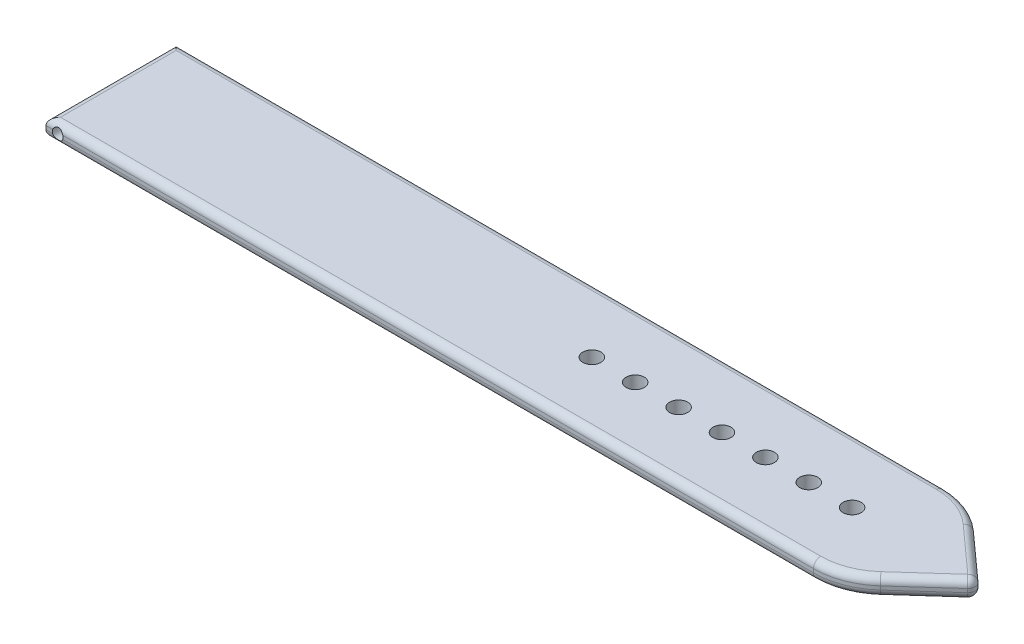
from build123d import *

# Parameters (mm, degrees)
BOSS_EXTRUDE1_DEPTH     = 1.25
FILLET1_R               = 10
FILLET2_R               = 1
FILLET3_R               = 1
SKETCH2_R               = 1.25
CUT_EXTRUDE1_DEPTH      = 3.5
LPATTERN1_COUNT         = 7
LPATTERN1_PITCH         = 6
SKETCH3_R               = 0.75
CUT_EXTRUDE2_DEPTH      = 10.0000001
CUT_EXTRUDE2_DEPTH_BACK = 10


with BuildPart() as part:
    # Sketch1 → Boss-Extrude1 (new body, symmetric)
    with BuildSketch(Plane(origin=(0, 0, 0), x_dir=(1, 0, 0), z_dir=(0, 1, 0))):
        Polygon((-59.638554217, 9), (-59.638554217, -9), (50.361445783, -9), (60.361445783, 0), (50.361445783, 9), align=None)
    extrude(amount=BOSS_EXTRUDE1_DEPTH, both=True)

    # Fillet1
    fillet1_edges = [part.edges().sort_by_distance(p)[0] for p in [
        (50.361445783, 0, 9),
        (50.361445783, 0, -9),
    ]]
    fillet(fillet1_edges, radius=FILLET1_R)

    # Fillet2
    fillet2_edges = [part.edges().sort_by_distance(p)[0] for p in [
        (60.361445783, 0, 0),
    ]]
    fillet(fillet2_edges, radius=FILLET2_R)

    # Fillet3
    fillet3_edges = [part.edges().sort_by_distance(p)[0] for p in [
        (-59.638554217, 1.25, 0),
        (-6.557234243, -1.25, -9),
        (-6.557234243, 1.25, -9),
        (56.374648223, -1.25, 3.588117804),
        (50.106723403, -1.25, 8.336204117),
        (50.106723403, -1.25, -8.336204117),
        (-6.557234243, 1.25, 9),
        (56.374648223, 1.25, 3.588117804),
        (50.106723403, 1.25, 8.336204117),
        (50.106723403, 1.25, -8.336204117),
        (56.374648223, -1.25, -3.588117804),
        (56.374648223, 1.25, -3.588117804),
        (59.866598667, -1.25, 0),
        (59.866598667, 1.25, 0),
        (-6.557234243, -1.25, 9),
        (-59.638554217, -1.25, 0),
    ]]
    fillet(fillet3_edges, radius=FILLET3_R)

    # Sketch2 → Cut-Extrude1 (cut, through all)
    with BuildSketch(Plane(origin=(0, 1.25, 0), x_dir=(1, 0, 0), z_dir=(0, 1, 0))):
        with Locations((42.866598667, 0)):
            Circle(SKETCH2_R)
    cut_extrude1 = extrude(amount=-CUT_EXTRUDE1_DEPTH, mode=Mode.SUBTRACT)

    # LPattern1: Cut-Extrude1 ×7
    with Locations(*[(-i * LPATTERN1_PITCH, 0, 0) for i in range(1, LPATTERN1_COUNT)]):
        add(cut_extrude1, mode=Mode.SUBTRACT)

    # Sketch3 → Cut-Extrude2 (cut, two sides)
    with BuildSketch(Plane.XY) as cut_extrude2_sk:
        with Locations((-58.019579169, 0)):
            Circle(SKETCH3_R)
    extrude(amount=CUT_EXTRUDE2_DEPTH, mode=Mode.SUBTRACT)
    extrude(cut_extrude2_sk.sketch, amount=-CUT_EXTRUDE2_DEPTH_BACK, mode=Mode.SUBTRACT)


solid = part.part
